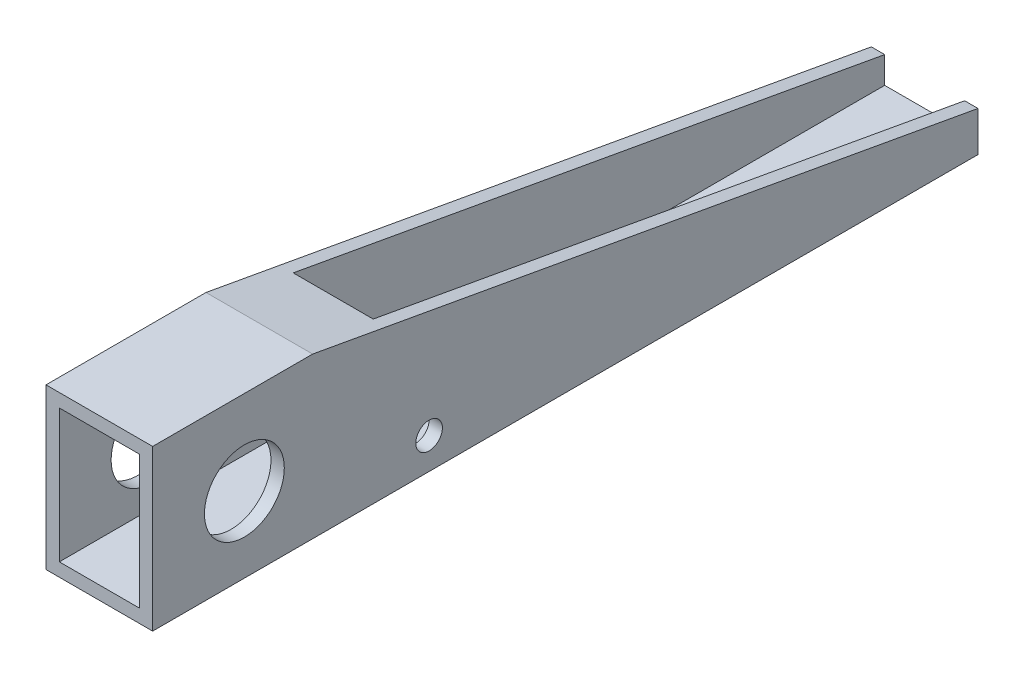
from build123d import *

# Parameters (mm, degrees)
SKETCH1_W           = 3.175
SKETCH1_H           = 38.1
SKETCH1_W_2         = 19.05
SKETCH1_H_2         = 3.175
BOSS_EXTRUDE1_DEPTH = 196.5706
SKETCH2_R           = 9.5123
SKETCH2_R_2         = 3.175
SIDE_CUT_DEPTH      = 26.4


with BuildPart() as part:
    # Sketch1 → Boss-Extrude1 (new body)
    with BuildSketch(Plane.XY):
        with Locations((1.5875, 19.05)):
            Rectangle(SKETCH1_W, SKETCH1_H)
        with Locations((12.7, 1.5875)):
            Rectangle(SKETCH1_W_2, SKETCH1_H_2)
        Polygon((22.225, 3.175), (22.225, 0), (25.4, 0), (25.4, 38.1), (22.225, 38.1), (22.225, 34.925), align=None)
        with Locations((12.7, 36.5125)):
            Rectangle(SKETCH1_W_2, SKETCH1_H_2)
    extrude(amount=BOSS_EXTRUDE1_DEPTH)

    # Sketch2 → Side cut (cut, through all)
    with BuildSketch(Plane(origin=(25.4, 0, 0), x_dir=(0, 0, -1), z_dir=(1, 0, 0))):
        with Locations((-174.7266, 17.991529913)):
            Circle(SKETCH2_R)
        with Locations((-130.736416842, 7.4258361)):
            Circle(SKETCH2_R_2)
        Polygon((-158.4706, 38.1), (0, 9.525), (0, 38.1), align=None)
    extrude(amount=-SIDE_CUT_DEPTH, mode=Mode.SUBTRACT)


solid = part.part
